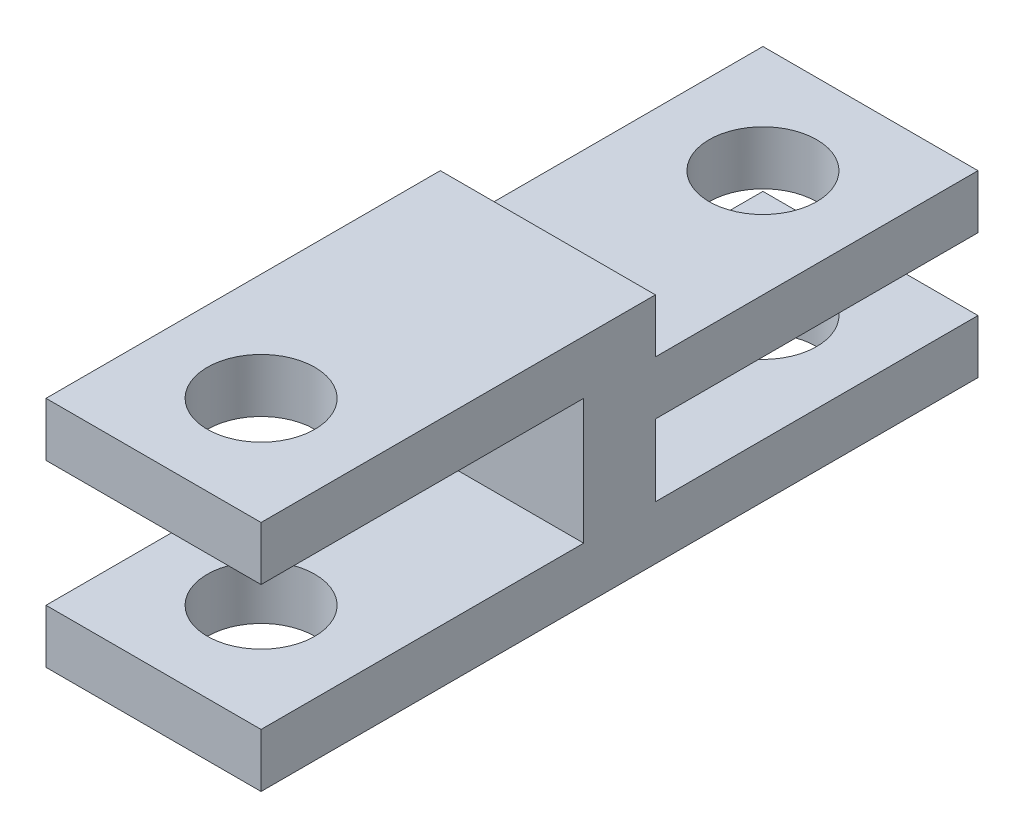
from build123d import *

# Parameters (mm, degrees)
BOSS_EXTRUDE1_DEPTH     = 6
SKETCH2_R               = 1.5
CUT_EXTRUDE1_DEPTH      = 1
CUT_EXTRUDE1_DEPTH_BACK = 7.5


with BuildPart() as part:
    # Sketch1 → Boss-Extrude1 (new body)
    with BuildSketch(Plane(origin=(0, 0, 0), x_dir=(0, 0, -1), z_dir=(1, 0, 0))):
        Polygon((0, 0), (-20, 0), (-20, 1.5), (-11, 1.5), (-11, 5), (-20, 5), (-20, 6.5), (-9, 6.5), (-9, 5), (0, 5), (0, 3.5), (-9, 3.5), (-9, 1.5), (0, 1.5), align=None)
    extrude(amount=BOSS_EXTRUDE1_DEPTH)

    # Sketch2 → Cut-Extrude1 (cut, two sides)
    with BuildSketch(Plane.XZ) as cut_extrude1_sk:
        with Locations((3, 3)):
            Circle(SKETCH2_R)
        with Locations((3, 17)):
            Circle(SKETCH2_R)
    extrude(amount=CUT_EXTRUDE1_DEPTH, mode=Mode.SUBTRACT)
    extrude(cut_extrude1_sk.sketch, amount=-CUT_EXTRUDE1_DEPTH_BACK, mode=Mode.SUBTRACT)


solid = part.part
